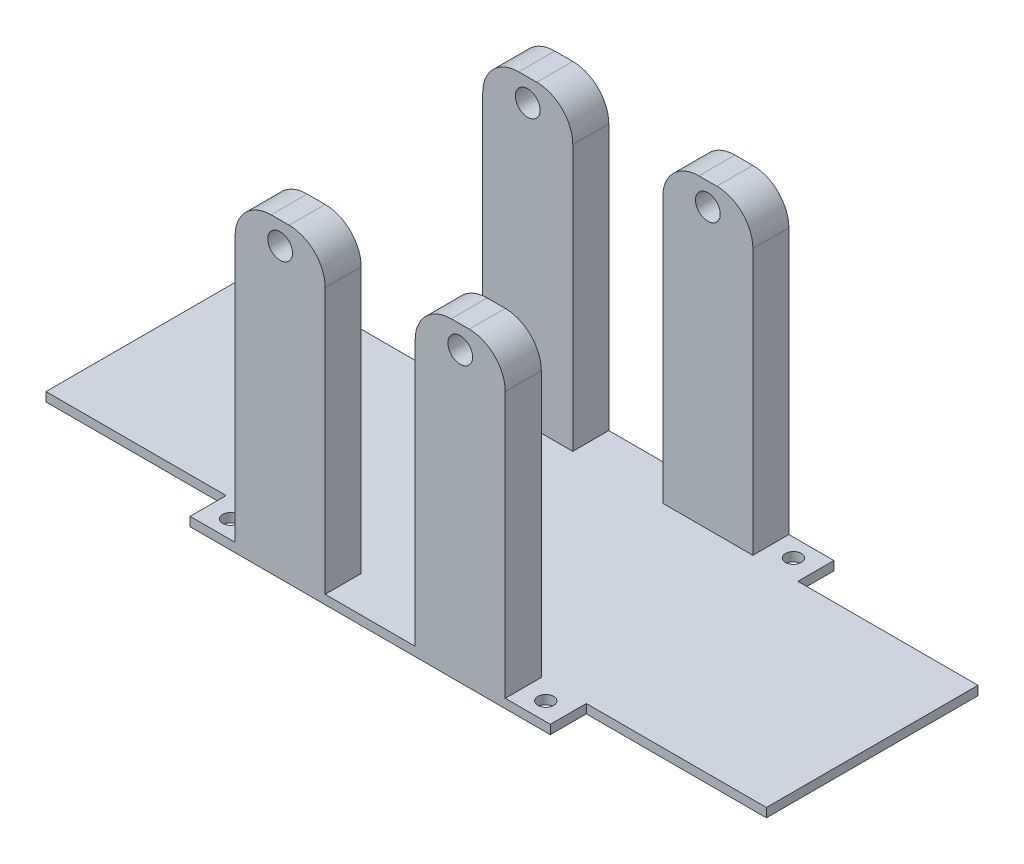
from build123d import *

# Parameters (mm, degrees)
SKETCH_1_R               = 1.75
EXTRUDE_1_DEPTH          = 2
SKETCH_2_W               = 20
SKETCH_2_H               = 8
EXTRUDE_2_DEPTH          = 67
SKETCH_3_R               = 2.75
CUT_EXTRUDE_1_DEPTH      = 1
CUT_EXTRUDE_1_DEPTH_BACK = 64
FILLET_1_R               = 8


with BuildPart() as part:
    # Эскиз1 → Бобышка-Вытянуть1 (new body)
    with BuildSketch(Plane(origin=(0, 0, 0), x_dir=(1, 0, 0), z_dir=(0, 1, 0))):
        Polygon((-80, -23.5), (-40, -23.5), (-40, -31.5), (40, -31.5), (40, -23.5), (80, -23.5), (80, 23.5), (40, 23.5), (40, 31.5), (-40, 31.5), (-40, 23.5), (-80, 23.5), align=None)
        with Locations((-35, 27.5)):
            Circle(SKETCH_1_R, mode=Mode.SUBTRACT)
        with Locations((35, 27.5)):
            Circle(SKETCH_1_R, mode=Mode.SUBTRACT)
        with Locations((35, -27.5)):
            Circle(SKETCH_1_R, mode=Mode.SUBTRACT)
        with Locations((-35, -27.5)):
            Circle(SKETCH_1_R, mode=Mode.SUBTRACT)
    extrude(amount=EXTRUDE_1_DEPTH)

    # Эскиз2 → Бобышка-Вытянуть2 (add)
    with BuildSketch(Plane(origin=(0, 2, 0), x_dir=(1, 0, 0), z_dir=(0, 1, 0))):
        with Locations((20, -27.5)):
            Rectangle(SKETCH_2_W, SKETCH_2_H)
        with Locations((-20, -27.5)):
            Rectangle(SKETCH_2_W, SKETCH_2_H)
        with Locations((20, 27.5)):
            Rectangle(SKETCH_2_W, SKETCH_2_H)
        with Locations((-20, 27.5)):
            Rectangle(SKETCH_2_W, SKETCH_2_H)
    extrude(amount=EXTRUDE_2_DEPTH)

    # Эскиз3 → Вырез-Вытянуть1 (cut, two sides)
    with BuildSketch(Plane.XY.offset(31.5)) as cut_extrude_1_sk:
        with Locations((-20, 64)):
            Circle(SKETCH_3_R)
        with Locations((20, 64)):
            Circle(SKETCH_3_R)
    extrude(amount=CUT_EXTRUDE_1_DEPTH, mode=Mode.SUBTRACT)
    extrude(cut_extrude_1_sk.sketch, amount=-CUT_EXTRUDE_1_DEPTH_BACK, mode=Mode.SUBTRACT)

    # Скругление1
    fillet_1_edges = [part.edges().sort_by_distance(p)[0] for p in [
        (-30, 69, 27.5),
        (-10, 69, 27.5),
        (30, 69, 27.5),
        (10, 69, 27.5),
        (10, 69, -27.5),
        (30, 69, -27.5),
        (-30, 69, -27.5),
        (-10, 69, -27.5),
    ]]
    fillet(fillet_1_edges, radius=FILLET_1_R)


solid = part.part
